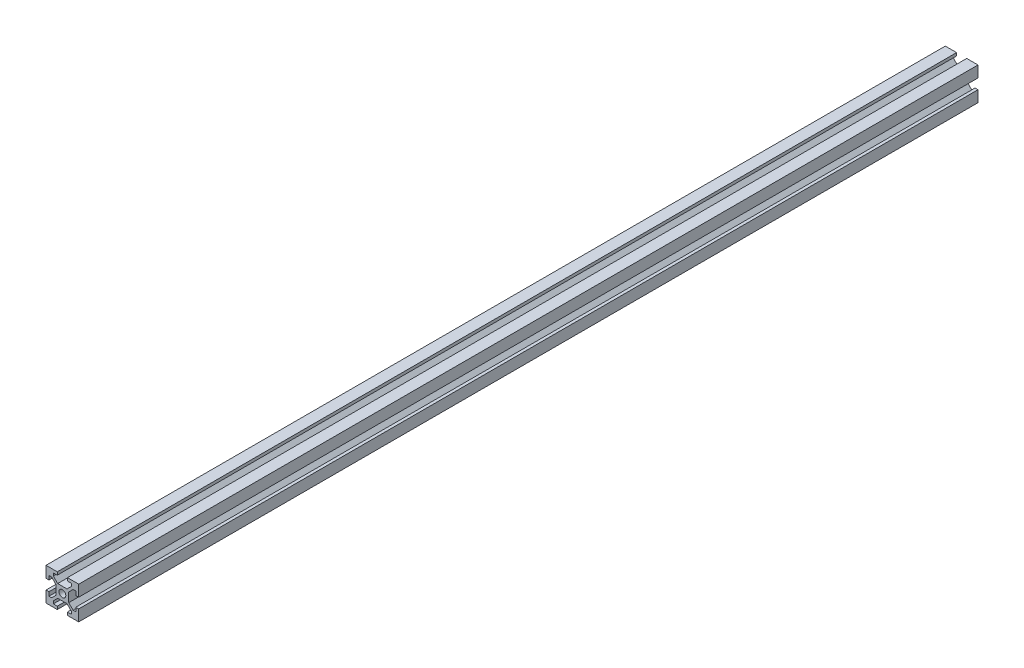
from build123d import *

# Parameters (mm, degrees)
BOSS_EXTRUDE1_DEPTH = 550
SKETCH2_R           = 2.1
CUT_EXTRUDE1_DEPTH  = 551
SKETCH3_R           = 2.1
CUT_EXTRUDE2_DEPTH  = 14.900660172


with BuildPart() as part:
    # Sketch1 → Boss-Extrude1 (new body)
    with BuildSketch(Plane.XY):
        Polygon((-3.1, 10), (-3.1, 8.200660172), (-5.5, 8.200660172), (-5.5, 6.560660172), (-2.84, 3.900660172), (2.84, 3.900660172), (5.5, 6.560660172), (5.5, 8.200660172), (3.1, 8.200660172), (3.1, 10), (10, 10), (10, 3.1), (8.200660172, 3.1), (8.200660172, 5.5), (6.560660172, 5.5), (3.900660172, 2.84), (3.900660172, -2.84), (6.560660172, -5.5), (8.200660172, -5.5), (8.200660172, -3.1), (10, -3.1), (10, -10), (3.1, -10), (3.1, -8.200660172), (5.5, -8.200660172), (5.5, -6.560660172), (2.84, -3.900660172), (-2.84, -3.900660172), (-5.5, -6.560660172), (-5.5, -8.200660172), (-3.1, -8.200660172), (-3.1, -10), (-10, -10), (-10, -3.1), (-8.200660172, -3.1), (-8.200660172, -5.5), (-6.560660172, -5.5), (-3.900660172, -2.84), (-3.900660172, 2.84), (-6.560660172, 5.5), (-8.200660172, 5.5), (-8.200660172, 3.1), (-10, 3.1), (-10, 10), align=None)
    extrude(amount=BOSS_EXTRUDE1_DEPTH)

    # Sketch2 → Cut-Extrude1 (cut, through all)
    with BuildSketch(Plane.XY.offset(550)):
        Circle(SKETCH2_R)
    extrude(amount=-CUT_EXTRUDE1_DEPTH, mode=Mode.SUBTRACT)

    # Sketch3 → Cut-Extrude2 (cut, through all)
    with BuildSketch(Plane(origin=(0, 3.900660172, 0), x_dir=(1, 0, 0), z_dir=(0, 1, 0))):
        with Locations((0, -275)):
            Circle(SKETCH3_R)
    extrude(amount=-CUT_EXTRUDE2_DEPTH, mode=Mode.SUBTRACT)


solid = part.part
